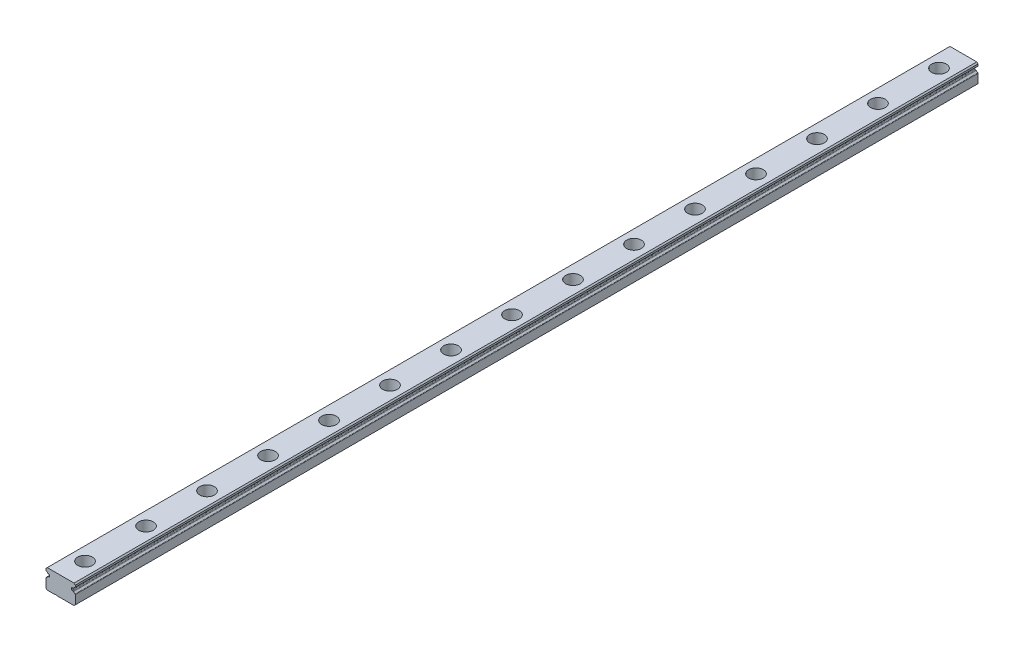
from build123d import *

# Parameters (mm, degrees)
BOSS_EXTRUDE1_DEPTH = 370
SKETCH2_R           = 1.75
CUT_EXTRUDE1_DEPTH  = 371.135110423
SKETCH2_3_R         = 3
CUT_EXTRUDE2_DEPTH  = 4.5


with BuildPart() as part:
    # Sketch1 → Boss-Extrude1 (new body)
    with BuildSketch(Plane.XY):
        with BuildLine():
            Line((5.5, -7.999998), (6, -7.499998))
            Line((6, -7.499998), (6, -3.85787958))
            ThreePointArc((6, -3.85787958), (5.9576137, -3.718608076), (5.844827586, -3.626562203))
            ThreePointArc((5.844827586, -3.626562203), (5.51524529, -3.424071402), (5.267205011, -3.12724985))
            ThreePointArc((5.267205011, -3.12724985), (5.185241933, -3.042985123), (5.073828324, -3.005495145))
            Line((5.073828324, -3.005495145), (4.728211064, -2.975257553))
            ThreePointArc((4.728211064, -2.975257553), (4.565680666, -2.89510643), (4.5, -2.726208878))
            Line((4.5, -2.726208878), (4.5, -2.273787121))
            ThreePointArc((4.5, -2.273787121), (4.565680666, -2.10488957), (4.728211064, -2.024738447))
            Line((4.728211064, -2.024738447), (5.09477657, -1.992668121))
            ThreePointArc((5.09477657, -1.992668121), (5.203244499, -1.957004425), (5.284541491, -1.876829678))
            ThreePointArc((5.284541491, -1.876829678), (5.527906161, -1.597614221), (5.844827586, -1.405915383))
            ThreePointArc((5.844827586, -1.405915383), (5.9576137, -1.31386951), (6, -1.174598006))
            Line((6, -1.174598006), (6, -0.5))
            Line((6, -0.5), (5.5, 0))
            Line((5.5, 0), (-5.5, 0))
            Line((-5.5, 0), (-6, -0.5))
            Line((-6, -0.5), (-6, -1.174598006))
            ThreePointArc((-6, -1.174598006), (-5.9576137, -1.31386951), (-5.844827586, -1.405915383))
            ThreePointArc((-5.844827586, -1.405915383), (-5.527906161, -1.597614221), (-5.284541491, -1.876829678))
            ThreePointArc((-5.284541491, -1.876829678), (-5.203244499, -1.957004425), (-5.09477657, -1.992668121))
            Line((-5.09477657, -1.992668121), (-4.728211064, -2.024738447))
            ThreePointArc((-4.728211064, -2.024738447), (-4.565680666, -2.10488957), (-4.5, -2.273787121))
            Line((-4.5, -2.273787121), (-4.5, -2.726208878))
            ThreePointArc((-4.5, -2.726208878), (-4.565680666, -2.89510643), (-4.728211064, -2.975257553))
            Line((-4.728211064, -2.975257553), (-5.073828324, -3.005495145))
            ThreePointArc((-5.073828324, -3.005495145), (-5.185241932, -3.042985123), (-5.267205011, -3.12724985))
            ThreePointArc((-5.267205011, -3.12724985), (-5.51524529, -3.424071402), (-5.844827586, -3.626562203))
            ThreePointArc((-5.844827586, -3.626562203), (-5.9576137, -3.718608076), (-6, -3.85787958))
            Line((-6, -3.85787958), (-6, -7.499998))
            Line((-6, -7.499998), (-5.5, -7.999998))
            Line((-5.5, -7.999998), (-2.4, -7.999998))
            ThreePointArc((-2.4, -7.999998), (-2, -7.799998), (-1.6, -7.999998))
            Line((-1.6, -7.999998), (5.5, -7.999998))
        make_face()
    extrude(amount=BOSS_EXTRUDE1_DEPTH)

    # Sketch2 → Cut-Extrude1 (cut, through all)
    with BuildSketch(Plane(origin=(0, 0, 0), x_dir=(1, 0, 0), z_dir=(0, 1, 0))):
        with Locations((0, -10)):
            Circle(SKETCH2_R)
        with Locations((0, -35)):
            Circle(SKETCH2_R)
        with Locations((0, -60)):
            Circle(SKETCH2_R)
        with Locations((0, -85)):
            Circle(SKETCH2_R)
        with Locations((0, -110)):
            Circle(SKETCH2_R)
        with Locations((0, -135)):
            Circle(SKETCH2_R)
        with Locations((0, -160)):
            Circle(SKETCH2_R)
        with Locations((0, -185)):
            Circle(SKETCH2_R)
        with Locations((0, -210)):
            Circle(SKETCH2_R)
        with Locations((0, -235)):
            Circle(SKETCH2_R)
        with Locations((0, -260)):
            Circle(SKETCH2_R)
        with Locations((0, -285)):
            Circle(SKETCH2_R)
        with Locations((0, -310)):
            Circle(SKETCH2_R)
        with Locations((0, -335)):
            Circle(SKETCH2_R)
        with Locations((0, -360)):
            Circle(SKETCH2_R)
        with Locations((0, -385)):
            Circle(SKETCH2_R)
        with Locations((0, -410)):
            Circle(SKETCH2_R)
    extrude(amount=-CUT_EXTRUDE1_DEPTH, mode=Mode.SUBTRACT)

    # Sketch2_3 → Cut-Extrude2 (cut)
    with BuildSketch(Plane(origin=(0, 0, 0), x_dir=(1, 0, 0), z_dir=(0, 1, 0))):
        with Locations((0, -10)):
            Circle(SKETCH2_3_R)
        with Locations((0, -35)):
            Circle(SKETCH2_3_R)
        with Locations((0, -60)):
            Circle(SKETCH2_3_R)
        with Locations((0, -85)):
            Circle(SKETCH2_3_R)
        with Locations((0, -110)):
            Circle(SKETCH2_3_R)
        with Locations((0, -135)):
            Circle(SKETCH2_3_R)
        with Locations((0, -160)):
            Circle(SKETCH2_3_R)
        with Locations((0, -185)):
            Circle(SKETCH2_3_R)
        with Locations((0, -210)):
            Circle(SKETCH2_3_R)
        with Locations((0, -235)):
            Circle(SKETCH2_3_R)
        with Locations((0, -260)):
            Circle(SKETCH2_3_R)
        with Locations((0, -285)):
            Circle(SKETCH2_3_R)
        with Locations((0, -310)):
            Circle(SKETCH2_3_R)
        with Locations((0, -335)):
            Circle(SKETCH2_3_R)
        with Locations((0, -360)):
            Circle(SKETCH2_3_R)
        with Locations((0, -385)):
            Circle(SKETCH2_3_R)
        with Locations((0, -410)):
            Circle(SKETCH2_3_R)
    extrude(amount=-CUT_EXTRUDE2_DEPTH, mode=Mode.SUBTRACT)


solid = part.part
